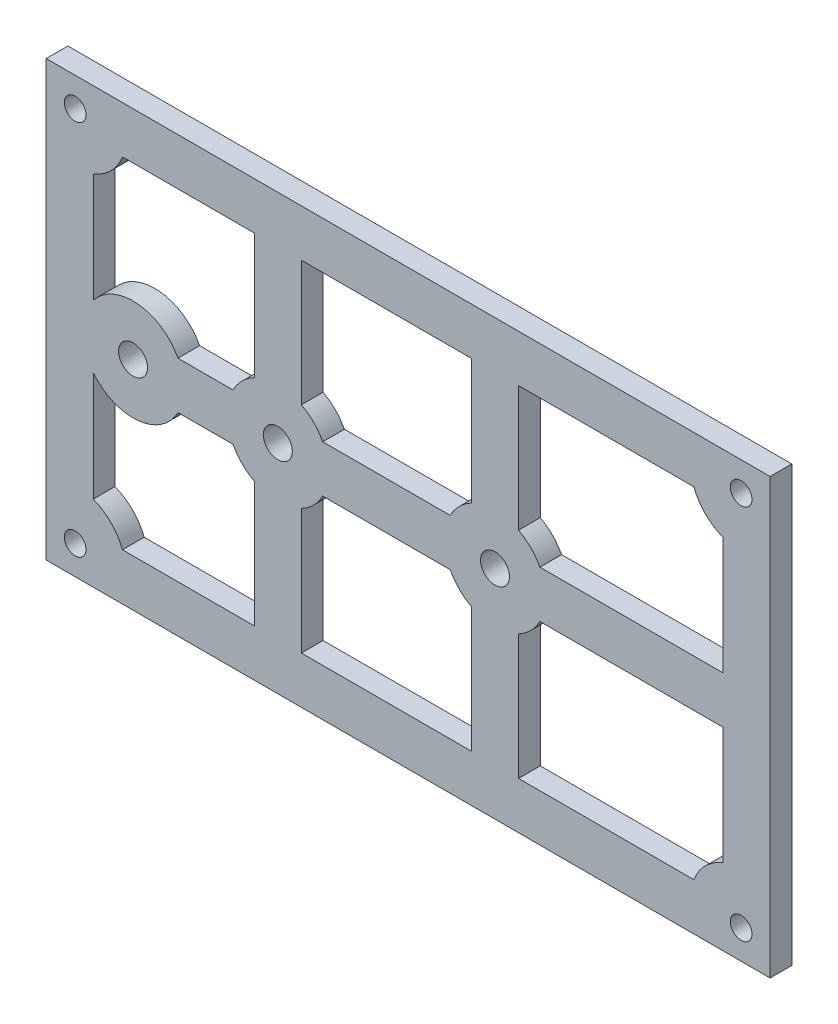
from build123d import *

# Parameters (mm, degrees)
SKETCH1_W           = 100
SKETCH1_H           = 60
BOSS_EXTRUDE1_DEPTH = 3
SKETCH2_R           = 2
SKETCH2_R_2         = 1.5
CUT_EXTRUDE1_DEPTH  = 3
SKETCH3_W           = 23.5
SKETCH3_H           = 20.25
CUT_EXTRUDE2_DEPTH  = 10
CUT_EXTRUDE3_DEPTH  = 10
SKETCH5_W           = 28.25
SKETCH5_H           = 20.25
CUT_EXTRUDE4_DEPTH  = 10
SKETCH6_R           = 7
BOSS_EXTRUDE2_DEPTH = 3
SKETCH7_R           = 2
CUT_EXTRUDE6_DEPTH  = 3
SKETCH9_R           = 7
SKETCH9_R_2         = 2
BOSS_EXTRUDE3_DEPTH = 3
BOSS_EXTRUDE4_DEPTH = 3


with BuildPart() as part:
    # Sketch1 → Boss-Extrude1 (new body)
    with BuildSketch(Plane.XY):
        Rectangle(SKETCH1_W, SKETCH1_H)
    extrude(amount=BOSS_EXTRUDE1_DEPTH)

    # Sketch2 → Cut-Extrude1 (cut)
    with BuildSketch(Plane.XY.offset(3)):
        with Locations((-38, 0)):
            Circle(SKETCH2_R)
        with Locations((-18, 0)):
            Circle(SKETCH2_R)
        with Locations((12, 0)):
            Circle(SKETCH2_R)
        with Locations((-46, 26)):
            Circle(SKETCH2_R_2)
        with Locations((46, 26)):
            Circle(SKETCH2_R_2)
        with Locations((46, -26)):
            Circle(SKETCH2_R_2)
        with Locations((-46, -26)):
            Circle(SKETCH2_R_2)
    extrude(amount=-CUT_EXTRUDE1_DEPTH, mode=Mode.SUBTRACT)

    # Sketch3 → Cut-Extrude2 (cut)
    with BuildSketch(Plane.XY.offset(3)):
        with Locations((-3, 13.375)):
            Rectangle(SKETCH3_W, SKETCH3_H)
    cut_extrude2 = extrude(amount=-CUT_EXTRUDE2_DEPTH, mode=Mode.SUBTRACT)

    # Mirror1: Cut-Extrude2 across plane
    add(cut_extrude2.mirror(Plane.ZX), mode=Mode.SUBTRACT)

    # Sketch4 → Cut-Extrude3 (cut)
    with BuildSketch(Plane.XY.offset(3)):
        with BuildLine():
            Line((-21.25, 23.5), (-39.461651585, 23.5))
            ThreePointArc((-39.461651585, 23.5), (-41.050252532, 21.050252532), (-43.5, 19.461651585))
            Line((-43.5, 19.461651585), (-43.5, 4.330127019))
            ThreePointArc((-43.5, 4.330127019), (-37.356495502, 6.970358812), (-31.800201616, 3.25))
            Line((-31.800201616, 3.25), (-24.199798384, 3.25))
            ThreePointArc((-24.199798384, 3.25), (-22.949747468, 4.949747468), (-21.25, 6.199798384))
            Line((-21.25, 6.199798384), (-21.25, 23.5))
        make_face()
    cut_extrude3 = extrude(amount=-CUT_EXTRUDE3_DEPTH, mode=Mode.SUBTRACT)

    # Mirror2: Cut-Extrude3 across plane
    add(cut_extrude3.mirror(Plane.ZX), mode=Mode.SUBTRACT)

    # Sketch5 → Cut-Extrude4 (cut)
    with BuildSketch(Plane.XY.offset(3)):
        with Locations((29.375, 13.375)):
            Rectangle(SKETCH5_W, SKETCH5_H)
    cut_extrude4 = extrude(amount=-CUT_EXTRUDE4_DEPTH, mode=Mode.SUBTRACT)

    # Sketch6 → Boss-Extrude2 (add)
    with BuildSketch(Plane.XY.offset(3)):
        with Locations((-18, 0)):
            Circle(SKETCH6_R)
    extrude(amount=-BOSS_EXTRUDE2_DEPTH)

    # Sketch7 → Cut-Extrude6 (cut)
    with BuildSketch(Plane.XY.offset(3)):
        with Locations((-18, 0)):
            Circle(SKETCH7_R)
    extrude(amount=-CUT_EXTRUDE6_DEPTH, mode=Mode.SUBTRACT)

    # Mirror4: Cut-Extrude4 across plane
    add(cut_extrude4.mirror(Plane.ZX), mode=Mode.SUBTRACT)

    # Sketch9 → Boss-Extrude3 (add)
    with BuildSketch(Plane.XY.offset(3)):
        with Locations((12, 0)):
            Circle(SKETCH9_R)
        with Locations((12, 0)):
            Circle(SKETCH9_R_2, mode=Mode.SUBTRACT)
    extrude(amount=-BOSS_EXTRUDE3_DEPTH)

    # Sketch11 → Boss-Extrude4 (add)
    with BuildSketch(Plane.XY.offset(3)):
        with BuildLine():
            Line((43.5, 19.461651585), (43.5, 23.5))
            Line((43.5, 23.5), (39.461651585, 23.5))
            ThreePointArc((39.461651585, 23.5), (41.050252532, 21.050252532), (43.5, 19.461651585))
        make_face()
    boss_extrude4 = extrude(amount=-BOSS_EXTRUDE4_DEPTH)

    # Mirror5: Boss-Extrude4 across plane
    add(boss_extrude4.mirror(Plane.ZX))


solid = part.part
